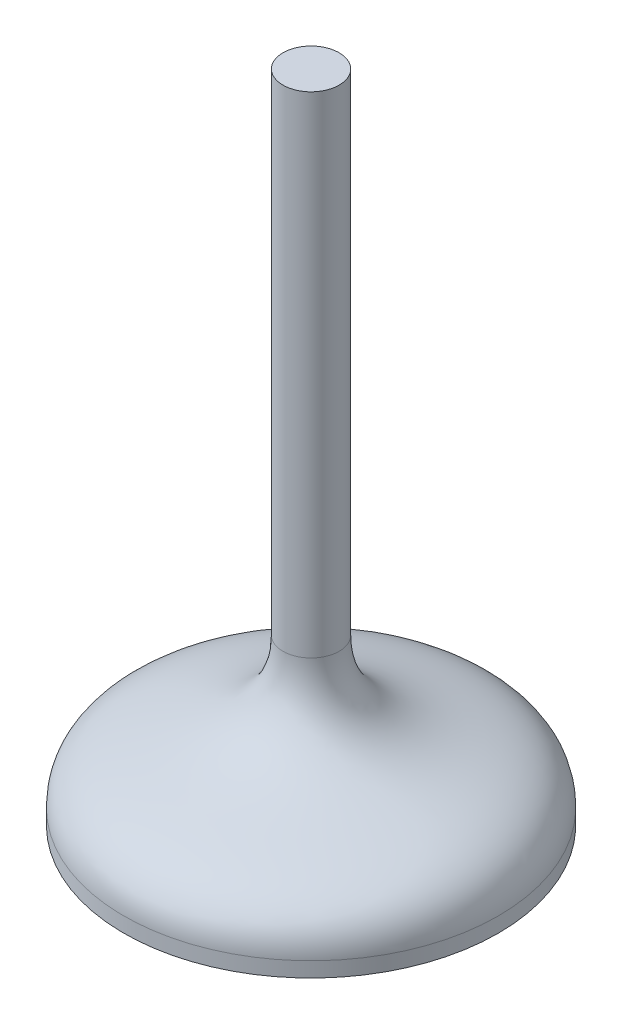
from build123d import *


with BuildPart() as part:
    # Sketch1 → Revolve1 (revolve)
    with BuildSketch(Plane.XY, mode=Mode.PRIVATE) as revolve1_sk:
        with BuildLine():
            Line((-10, 0.8), (-10, 0))
            Line((-10, 0), (0, 0))
            Line((0, 0), (0, 35))
            Line((0, 35), (-1.5, 35))
            Line((-1.5, 35), (-1.5, 8.8))
            add(Edge.make_bspline(
                [(-10, 0.8), (-10, 5.143785025), (-1.5, 2.706204915), (-1.5, 8.8)],
                knots=[0, 0, 0, 0, 1, 1, 1, 1], degree=3))
        make_face()
    revolve(revolve1_sk.sketch.rotate(Axis((0, 0, 0), (0, 1, 0)), 180), axis=Axis((0, 0, 0), (0, 1, 0)))  # turned: the seam where the file's is


solid = part.part
